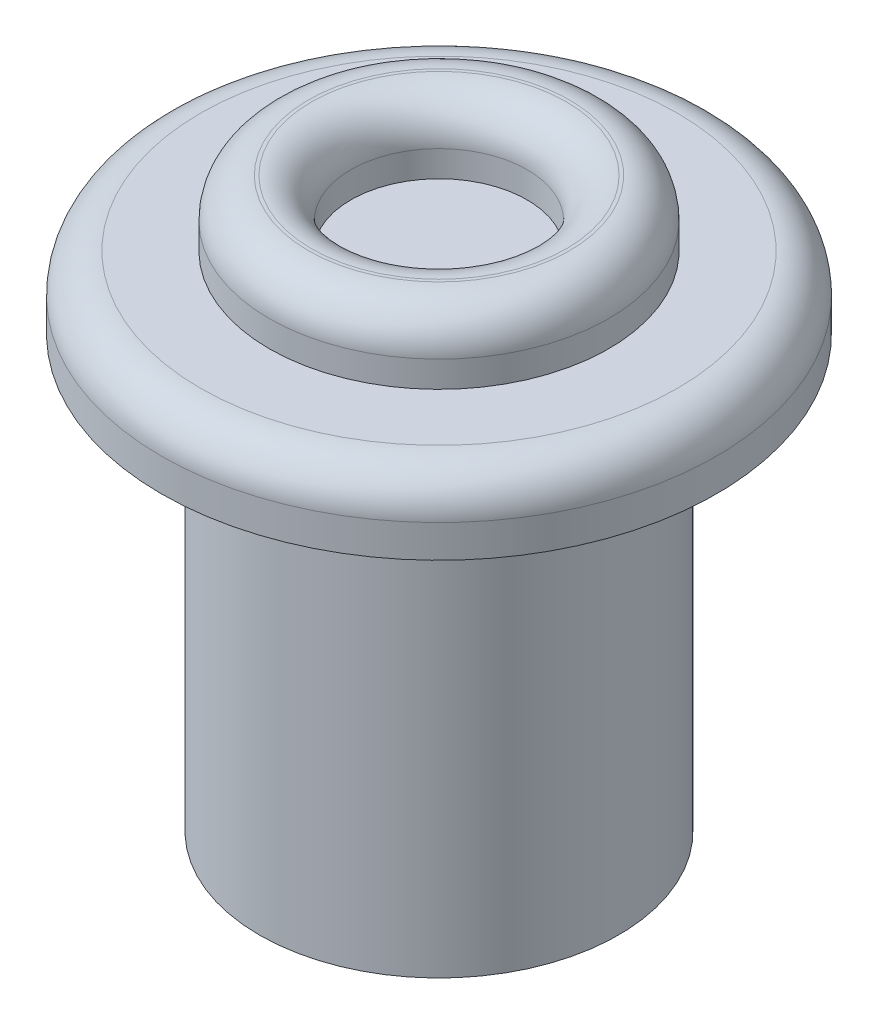
from build123d import *

# Parameters (mm, degrees)
SKETCH1_R           = 2.75
SKETCH1_R_2         = 1.4
BOSS_EXTRUDE1_DEPTH = 6.6
SKETCH2_R           = 4.25
BOSS_EXTRUDE2_DEPTH = 1.1
SKETCH3_R           = 2.6
SKETCH3_R_2         = 1.35
BOSS_EXTRUDE3_DEPTH = 1
FILLET1_R           = 0.6


with BuildPart() as part:
    # Sketch1 → Boss-Extrude1 (new body)
    with BuildSketch(Plane(origin=(0, 0, 0), x_dir=(1, 0, 0), z_dir=(0, 1, 0))):
        Circle(SKETCH1_R)
        Circle(SKETCH1_R_2, mode=Mode.SUBTRACT)
    extrude(amount=BOSS_EXTRUDE1_DEPTH)

    # Sketch2 → Boss-Extrude2 (add)
    with BuildSketch(Plane(origin=(0, 6.6, 0), x_dir=(1, 0, 0), z_dir=(0, 1, 0))):
        Circle(SKETCH2_R)
    extrude(amount=BOSS_EXTRUDE2_DEPTH)

    # Sketch3 → Boss-Extrude3 (add)
    with BuildSketch(Plane(origin=(0, 7.7, 0), x_dir=(1, 0, 0), z_dir=(0, 1, 0))):
        Circle(SKETCH3_R)
        Circle(SKETCH3_R_2, mode=Mode.SUBTRACT)
    extrude(amount=BOSS_EXTRUDE3_DEPTH)

    # Fillet1
    fillet1_edges = [part.edges().sort_by_distance(p)[0] for p in [
        (-2.6, 8.7, 0),
        (-1.35, 8.7, 0),
        (-4.25, 7.7, 0),
    ]]
    fillet(fillet1_edges, radius=FILLET1_R)


solid = part.part
